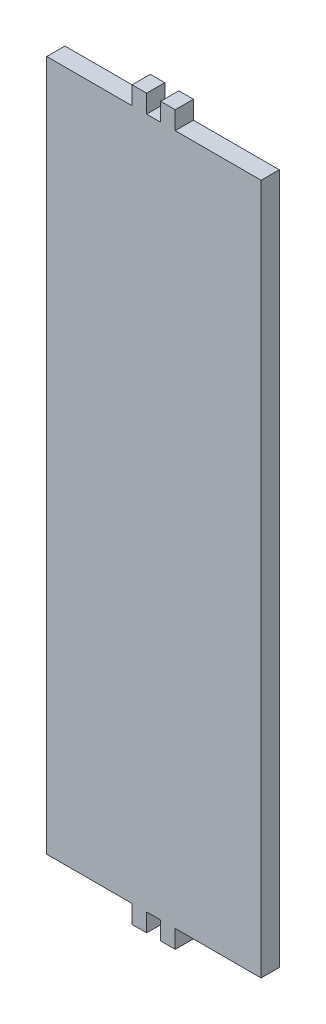
from build123d import *

# Parameters (mm, degrees)
SKETCH1_W           = 49.8113264
SKETCH1_H           = 241.325
SKETCH1_W_2         = 5
SKETCH1_H_2         = 6.35
SKETCH1_W_3         = 25
BOSS_EXTRUDE1_DEPTH = 6.35
BOSS_EXTRUDE2_DEPTH = 6.35


with BuildPart() as part:
    # Sketch1 → Boss-Extrude1 (new body)
    with BuildSketch(Plane.XY):
        Rectangle(SKETCH1_W, SKETCH1_H)
        with Locations((17.4056632, 123.8375)):
            Rectangle(SKETCH1_W_2, SKETCH1_H_2)
        with Locations((7.4056632, 123.8375)):
            Rectangle(SKETCH1_W_2, SKETCH1_H_2)
        with Locations((7.4056632, -123.8375)):
            Rectangle(SKETCH1_W_2, SKETCH1_H_2)
        with Locations((17.4056632, -123.8375)):
            Rectangle(SKETCH1_W_2, SKETCH1_H_2)
        with Locations((37.4056632, 0)):
            Rectangle(SKETCH1_W_3, SKETCH1_H)
    extrude(amount=BOSS_EXTRUDE1_DEPTH)

    # Sketch2 → Boss-Extrude2 (add)
    with BuildSketch(Plane.XY.offset(6.35)):
        Polygon((49.9463032, -120.70314), (49.9463032, 120.70314), (19.9463032, 120.70314), (19.9463032, 127.05314), (14.8650232, 127.05314), (14.8650232, 120.70314), (9.9463032, 120.70314), (9.9463032, 127.05314), (4.8650232, 127.05314), (4.8650232, 120.70314), (-24.9463032, 120.70314), (-24.9463032, -120.70314), (4.8650232, -120.70314), (4.8650232, -127.05314), (9.9463032, -127.05314), (9.9463032, -120.70314), (14.8650232, -120.70314), (14.8650232, -127.05314), (19.9463032, -127.05314), (19.9463032, -120.70314), align=None)
    extrude(amount=-BOSS_EXTRUDE2_DEPTH)


solid = part.part
